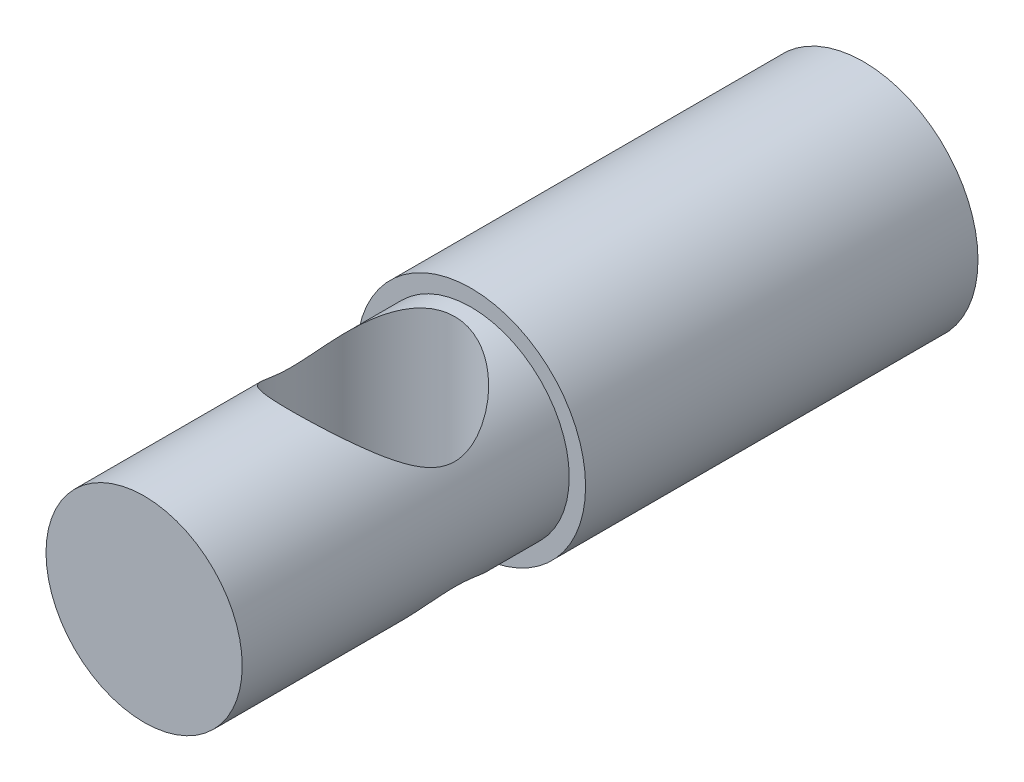
from build123d import *

# Parameters (mm, degrees)
CROQUIS1_R              = 3.5
SALIENTE_EXTRUIR1_DEPTH = 21
CROQUIS2_R              = 3.5
CROQUIS2_R_2            = 3
CORTAR_EXTRUIR1_DEPTH   = 10
CROQUIS3_R              = 2.5
CORTAR_EXTRUIR2_DEPTH   = 10
CROQUIS4_R              = 3.5
SALIENTE_EXTRUIR2_DEPTH = 1


with BuildPart() as part:
    # Croquis1 → Saliente-Extruir1 (new body)
    with BuildSketch(Plane.XY):
        Circle(CROQUIS1_R)
    extrude(amount=SALIENTE_EXTRUIR1_DEPTH)

    # Croquis2 → Cortar-Extruir1 (cut)
    with BuildSketch(Plane.XY.offset(21)):
        Circle(CROQUIS2_R)
        Circle(CROQUIS2_R_2, mode=Mode.SUBTRACT)
    extrude(amount=-CORTAR_EXTRUIR1_DEPTH, mode=Mode.SUBTRACT)

    # Croquis3 → Cortar-Extruir2 (cut)
    with BuildSketch(Plane(origin=(0, 0, 0), x_dir=(1, 0, 0), z_dir=(0, 1, 0))):
        with Locations((0, -14)):
            Circle(CROQUIS3_R)
    cortar_extruir2 = extrude(amount=-CORTAR_EXTRUIR2_DEPTH, mode=Mode.SUBTRACT)

    # Simetría1: Cortar-Extruir2 across plane
    add(cortar_extruir2.mirror(Plane.ZX), mode=Mode.SUBTRACT)

    # Croquis4 → Saliente-Extruir2 (add)
    with BuildSketch(Plane(origin=(0, 0, 0), x_dir=(-1, 0, 0), z_dir=(0, 0, -1))):
        Circle(CROQUIS4_R)
    extrude(amount=SALIENTE_EXTRUIR2_DEPTH)


solid = part.part
